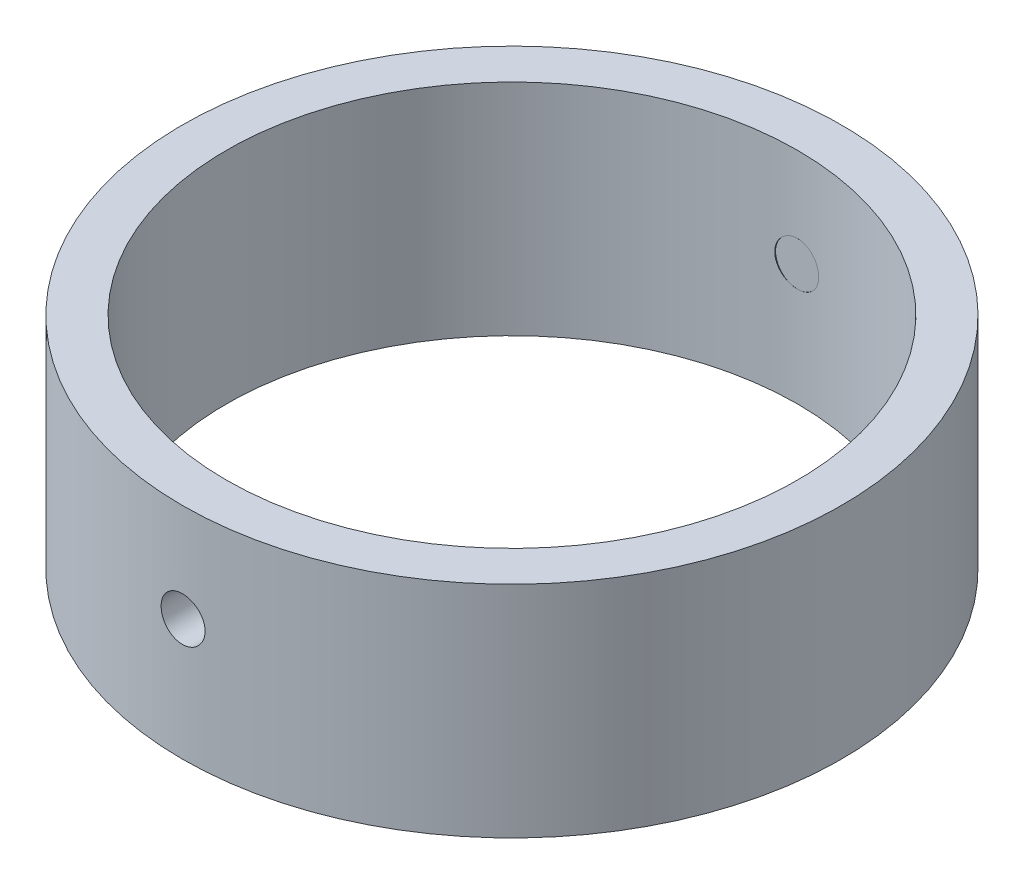
from build123d import *

# Parameters (mm, degrees)
SKETCH_1_R          = 15
SKETCH_1_R_2        = 13
EXTRUDE_1_DEPTH     = 10
SKETCH_2_R          = 1
CUT_EXTRUDE_1_DEPTH = 34.301651611


with BuildPart() as part:
    # 草图1 → 凸台-拉伸1 (new body)
    with BuildSketch(Plane(origin=(0, 0, 0), x_dir=(1, 0, 0), z_dir=(0, 1, 0))):
        with Locations(Location((0, 0, 0), (0, 0, 270))):
            Circle(SKETCH_1_R)
        with Locations(Location((0, 0, 0), (0, 0, 270))):
            Circle(SKETCH_1_R_2, mode=Mode.SUBTRACT)
    extrude(amount=EXTRUDE_1_DEPTH)

    # 草图2 → 切除-拉伸1 (cut, through all)
    with BuildSketch(Plane(origin=(0, 0, -13), x_dir=(-1, 0, 0), z_dir=(0, 0, -1))):
        with Locations(Location((0, 5.523046221, 0), (0, 0, 90.000000034))):
            Circle(SKETCH_2_R)
    extrude(amount=-CUT_EXTRUDE_1_DEPTH, mode=Mode.SUBTRACT)


solid = part.part
